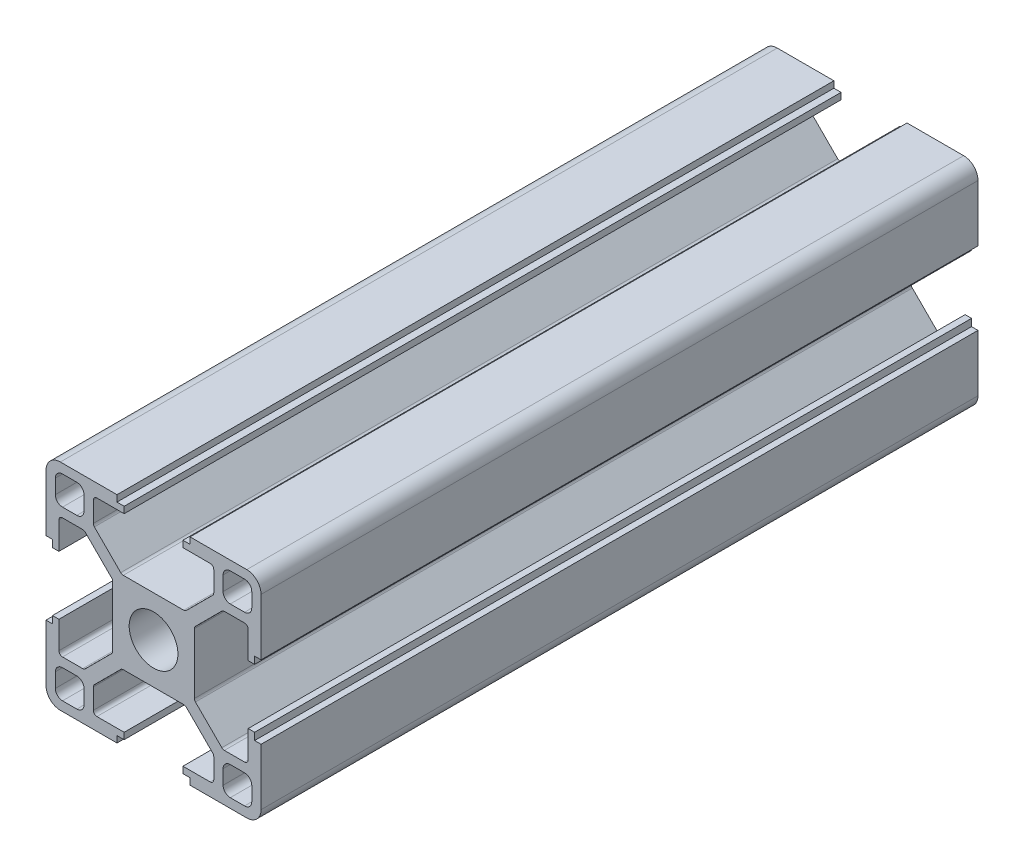
from build123d import *

# Parameters (mm, degrees)
SKETCH_1_W                       = 4
SKETCH_1_H                       = 4
EXTRUDE_1_DEPTH                  = 100
FILLET_1_R                       = 1
FILLET_2_R                       = 2
FILLET_3_R                       = 0.5
PATTERN_CIRCULAR_1_COUNT         = 4
FILLET_1_OF_PATTERN_CIRCULAR_1_R = 1
FILLET_2_OF_PATTERN_CIRCULAR_1_R = 2
FILLET_3_OF_PATTERN_CIRCULAR_1_R = 0.5
SKETCH_2_R                       = 3.4
CUT_EXTRUDE_1_DEPTH              = 101
SKETCH_3_R                       = 4
CUT_EXTRUDE_2_DEPTH              = 15


with BuildPart() as part:
    # 草图1 → 凸台-拉伸1 (new body)
    with BuildSketch(Plane.XY):
        Polygon((5.7, 0), (5.7, 4.427207794), (9.672792206, 8.4), (13.2, 8.4), (13.2, 4.1), (14.1, 4.1), (14.1, 5.1), (15, 5.1), (15, 15), (5.1, 15), (5.1, 14.1), (4.1, 14.1), (4.1, 13.2), (8.4, 13.2), (8.4, 9.672792206), (4.427207794, 5.7), (0, 5.7), (0, 0), align=None)
        with Locations((11.7, 11.7)):
            Rectangle(SKETCH_1_W, SKETCH_1_H, mode=Mode.SUBTRACT)
    extrude_1 = extrude(amount=EXTRUDE_1_DEPTH)

    # 圆角1
    fillet_1_edges = [part.edges().sort_by_distance(p)[0] for p in [
        (13.7, 9.7, 50),
        (13.7, 13.7, 50),
        (9.7, 13.7, 50),
        (9.7, 9.7, 50),
    ]]
    fillet(fillet_1_edges, radius=FILLET_1_R)

    # 圆角2
    fillet_2_edges = [part.edges().sort_by_distance(p)[0] for p in [
        (15, 15, 50),
    ]]
    fillet(fillet_2_edges, radius=FILLET_2_R)

    # 圆角3
    fillet_3_edges = [part.edges().sort_by_distance(p)[0] for p in [
        (4.427207794, 5.7, 50),
        (8.4, 9.672792206, 50),
        (8.4, 13.2, 50),
        (13.2, 8.4, 50),
        (9.672792206, 8.4, 50),
        (5.7, 4.427207794, 50),
    ]]
    fillet(fillet_3_edges, radius=FILLET_3_R)

    # 阵列(圆周)1: 凸台-拉伸1 ×4 about axis
    pattern_circular_1_axis = Axis((0, 0, 0), (0, 0, 1))
    for i in range(1, PATTERN_CIRCULAR_1_COUNT):
        add(extrude_1.rotate(pattern_circular_1_axis, i * 360 / PATTERN_CIRCULAR_1_COUNT))

    # 圆角1 of 阵列(圆周)1
    fillet_1_of_pattern_circular_1_edges = [part.edges().sort_by_distance(p)[0] for p in [
        (-9.7, 13.7, 50),
        (-13.7, 13.7, 50),
        (-13.7, 9.7, 50),
        (-9.7, 9.7, 50),
        (-13.7, -9.7, 50),
        (-13.7, -13.7, 50),
        (-9.7, -13.7, 50),
        (-9.7, -9.7, 50),
        (9.7, -13.7, 50),
        (13.7, -13.7, 50),
        (13.7, -9.7, 50),
        (9.7, -9.7, 50),
    ]]
    fillet(fillet_1_of_pattern_circular_1_edges, radius=FILLET_1_OF_PATTERN_CIRCULAR_1_R)

    # 圆角2 of 阵列(圆周)1
    fillet_2_of_pattern_circular_1_edges = [part.edges().sort_by_distance(p)[0] for p in [
        (-15, 15, 50),
        (-15, -15, 50),
        (15, -15, 50),
    ]]
    fillet(fillet_2_of_pattern_circular_1_edges, radius=FILLET_2_OF_PATTERN_CIRCULAR_1_R)

    # 圆角3 of 阵列(圆周)1
    fillet_3_of_pattern_circular_1_edges = [part.edges().sort_by_distance(p)[0] for p in [
        (-5.7, 4.427207794, 50),
        (-9.672792206, 8.4, 50),
        (-13.2, 8.4, 50),
        (-8.4, 13.2, 50),
        (-8.4, 9.672792206, 50),
        (-4.427207794, 5.7, 50),
        (-4.427207794, -5.7, 50),
        (-8.4, -9.672792206, 50),
        (-8.4, -13.2, 50),
        (-13.2, -8.4, 50),
        (-9.672792206, -8.4, 50),
        (-5.7, -4.427207794, 50),
        (5.7, -4.427207794, 50),
        (9.672792206, -8.4, 50),
        (13.2, -8.4, 50),
        (8.4, -13.2, 50),
        (8.4, -9.672792206, 50),
        (4.427207794, -5.7, 50),
    ]]
    fillet(fillet_3_of_pattern_circular_1_edges, radius=FILLET_3_OF_PATTERN_CIRCULAR_1_R)

    # 草图2 → 切除-拉伸1 (cut, through all)
    with BuildSketch(Plane.XY.offset(100)):
        Circle(SKETCH_2_R)
    extrude(amount=-CUT_EXTRUDE_1_DEPTH, mode=Mode.SUBTRACT)

    # 草图3 → 切除-拉伸2 (cut, symmetric)
    with BuildSketch(Plane(origin=(0, 0, 0), x_dir=(0, 0, -1), z_dir=(1, 0, 0))):
        with Locations((-80.8, 0)):
            Circle(SKETCH_3_R)
    extrude(amount=CUT_EXTRUDE_2_DEPTH, both=True, mode=Mode.SUBTRACT)


solid = part.part
